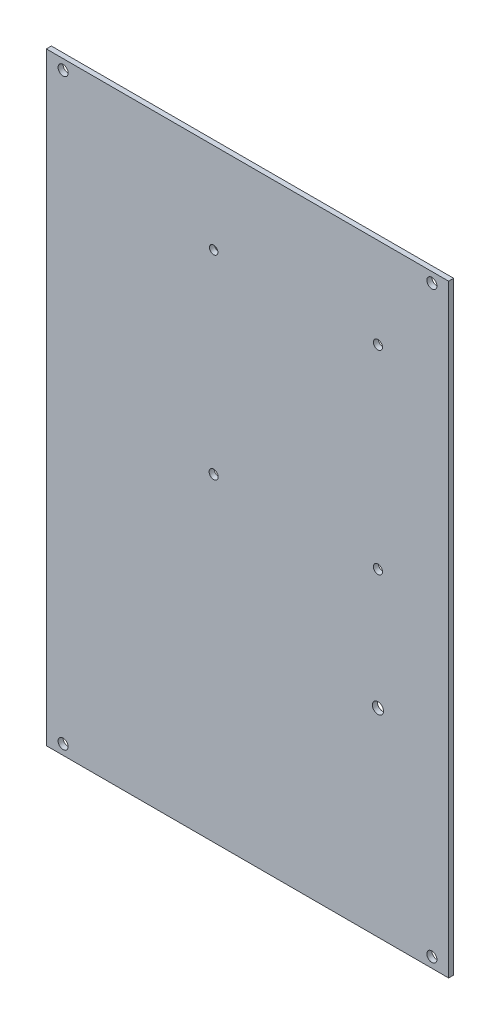
from build123d import *

# Parameters (mm, degrees)
SKETCH_1_W      = 1200
SKETCH_1_H      = 1800
SKETCH_1_R      = 15
SKETCH_1_R_2    = 13.5
SKETCH_1_R_3    = 12.5
SKETCH_1_R_4    = 16.51
EXTRUDE_1_DEPTH = 3
SCALE_1_SCALE_X = 0.1
SCALE_1_SCALE_Y = 0.1
SCALE_1_SCALE_Z = 0.5


with BuildPart() as part:
    # 草图1 → 凸台-拉伸1 (new body)
    with BuildSketch(Plane.XY):
        with Locations((911.452724683, 0)):
            Rectangle(SKETCH_1_W, SKETCH_1_H)
        with Locations((361.452724683, 870)):
            Circle(SKETCH_1_R, mode=Mode.SUBTRACT)
        with Locations((810.562965783, 50.494241768)):
            Circle(SKETCH_1_R_2, mode=Mode.SUBTRACT)
        with Locations((1300.562956283, 50.494241768)):
            Circle(SKETCH_1_R_2, mode=Mode.SUBTRACT)
        with Locations((1300.562956283, 630.408028512)):
            Circle(SKETCH_1_R_2, mode=Mode.SUBTRACT)
        with Locations((810.562965783, 630.40802886)):
            Circle(SKETCH_1_R_3, mode=Mode.SUBTRACT)
        with Locations((1461.452724683, 870)):
            Circle(SKETCH_1_R, mode=Mode.SUBTRACT)
        with Locations((361.452724683, -870)):
            Circle(SKETCH_1_R, mode=Mode.SUBTRACT)
        with Locations((1461.452724683, -870)):
            Circle(SKETCH_1_R, mode=Mode.SUBTRACT)
        with Locations((1300.562956283, -308.203766853)):
            Circle(SKETCH_1_R_4, mode=Mode.SUBTRACT)
    extrude(amount=EXTRUDE_1_DEPTH)


with BuildPart() as part_1:
    # 缩放比例1: scaled about (911.140997431, -0.215536981, 1.5)
    add(part.part.scale((SCALE_1_SCALE_X, SCALE_1_SCALE_Y, SCALE_1_SCALE_Z), about=(911.140997431, -0.215536981, 1.5)))


solid = part_1.part
